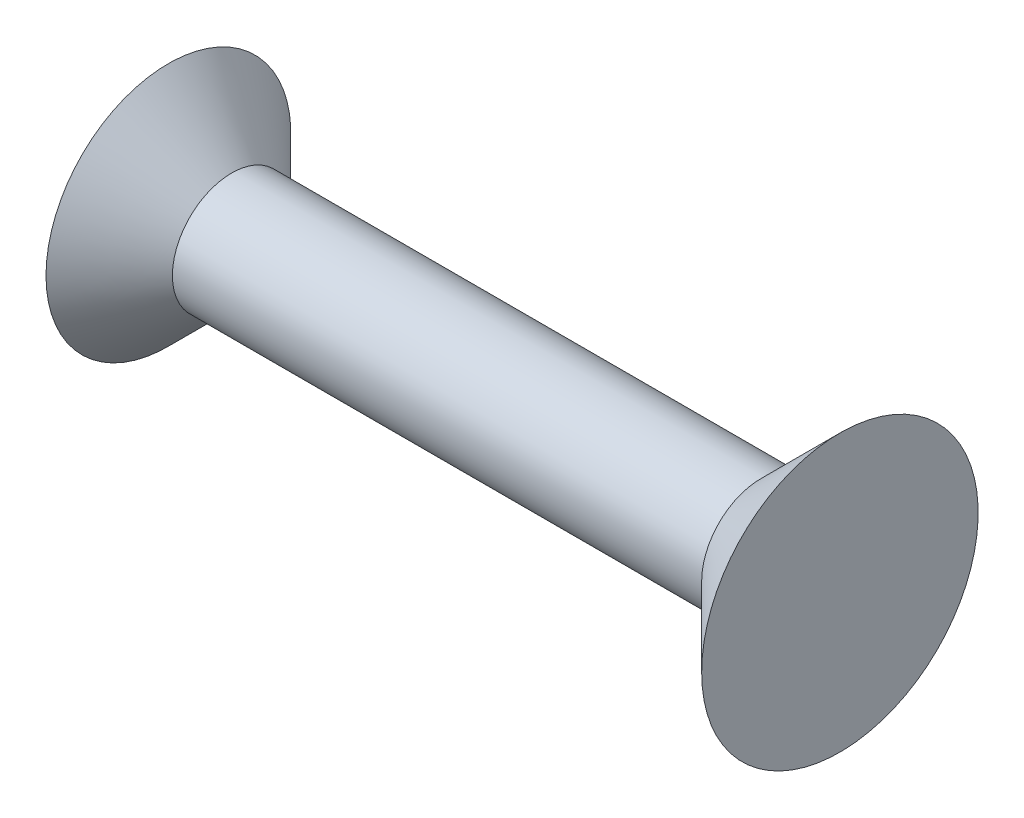
from build123d import *


with BuildPart() as part:
    # Esquisse1 → Révolution1 (revolve)
    with BuildSketch(Plane.XY, mode=Mode.PRIVATE) as r_volution1_sk:
        Polygon((0, 0), (0, 3.5), (-2, 1.5), (-15.4, 1.5), (-17, 3.1), (-17, 0), align=None)
    revolve(r_volution1_sk.sketch.rotate(Axis((0, 0, 0), (1, 0, 0)), 90), axis=Axis((0, 0, 0), (1, 0, 0)))  # turned: the seam where the file's is


solid = part.part
